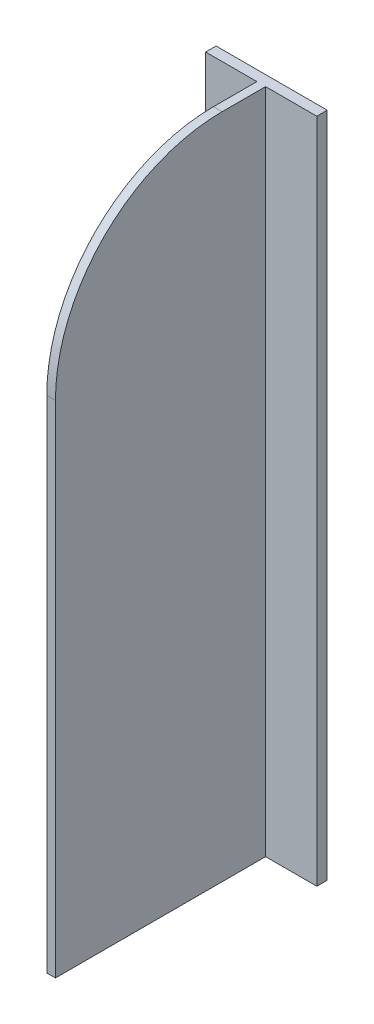
from build123d import *

# Parameters (mm, degrees)
BOSS_EXTRUDE1_DEPTH = 304.8
FILLET1_R           = 152.4


with BuildPart() as part:
    # Sketch1 → Boss-Extrude1 (new body, symmetric)
    with BuildSketch(Plane(origin=(0, 0, 0), x_dir=(-1, 0, 0), z_dir=(0, 1, 0))):
        Polygon((-50.8, 0), (50.8, 0), (50.8, 9.525), (3.96875, 9.525), (3.96875, 201.6125), (-3.96875, 201.6125), (-3.96875, 9.525), (-50.8, 9.525), align=None)
    extrude(amount=BOSS_EXTRUDE1_DEPTH, both=True)

    # Fillet1
    fillet1_edges = [part.edges().sort_by_distance(p)[0] for p in [
        (0, 304.8, 201.6125),
    ]]
    fillet(fillet1_edges, radius=FILLET1_R)


solid = part.part
